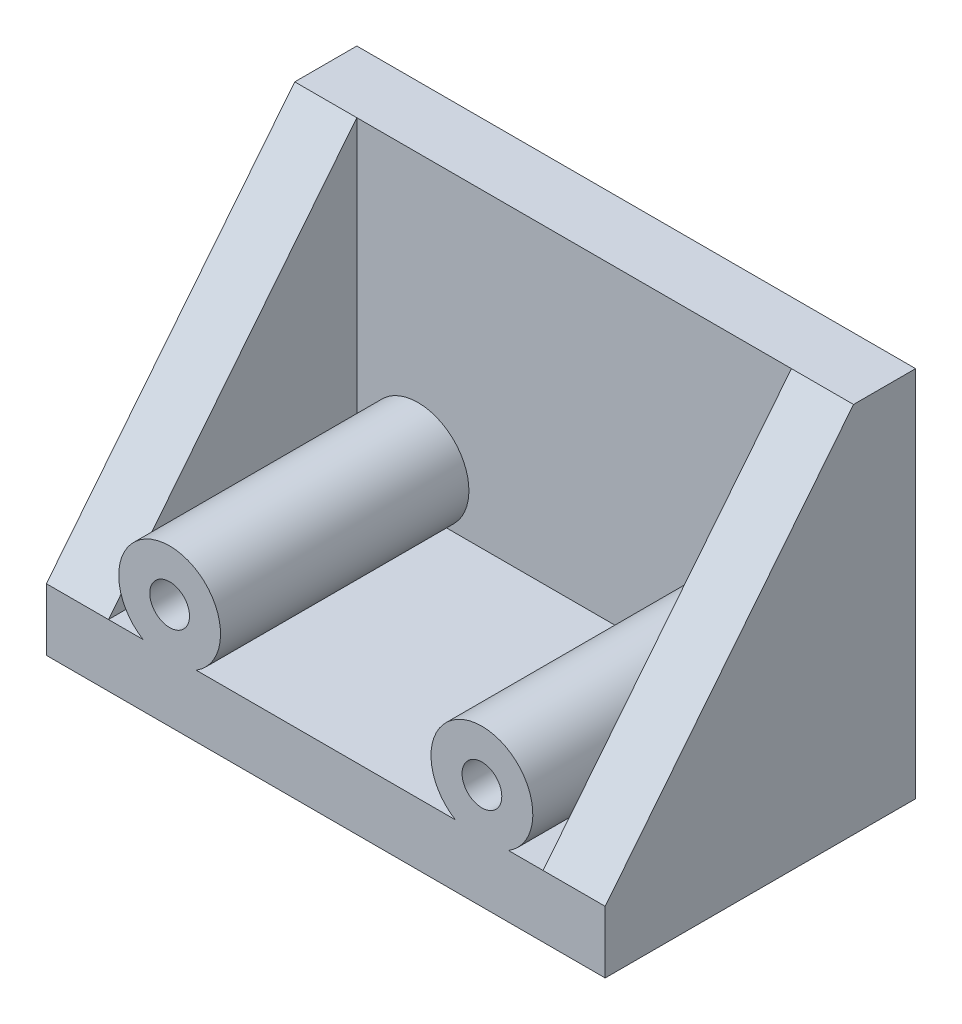
from build123d import *

# Parameters (mm, degrees)
SKETCH1_W            = 180
SKETCH1_H            = 120
BOSS_EXTRUDE1_DEPTH  = 20
SKETCH4_W            = 180
SKETCH4_H            = 100
BOSS_EXTRUDE4_DEPTH  = 20
BOSS_EXTRUDE5_DEPTH  = 20
SKETCH6_R            = 6.4
BOSS_EXTRUDE11_DEPTH = 80


with BuildPart() as part:
    # Sketch1 → Boss-Extrude1 (new body)
    with BuildSketch(Plane.XY):
        Rectangle(SKETCH1_W, SKETCH1_H)
    extrude(amount=BOSS_EXTRUDE1_DEPTH)

    # Sketch4 → Boss-Extrude4 (add)
    with BuildSketch(Plane(origin=(0, -60, 0), x_dir=(-1, 0, 0), z_dir=(0, -1, 0))):
        with Locations((0, -50)):
            Rectangle(SKETCH4_W, SKETCH4_H)
    extrude(amount=-BOSS_EXTRUDE4_DEPTH)

    # Sketch5 → Boss-Extrude5 (add)
    with BuildSketch(Plane(origin=(90, 0, 0), x_dir=(0, 0, -1), z_dir=(1, 0, 0))):
        Polygon((-100, -40), (-20, -40), (-20, 60), align=None)
    boss_extrude5 = extrude(amount=-BOSS_EXTRUDE5_DEPTH)

    # Mirror2: Boss-Extrude5 across plane
    add(boss_extrude5.mirror(Plane(origin=(0, 0, 0), x_dir=(0, 0, 1), z_dir=(1, 0, 0))))

    # Sketch6 → Boss-Extrude11 (add)
    with BuildSketch(Plane.XY.offset(20)):
        with BuildLine():
            Line((-41.754337398, -40), (-58.837662602, -40))
            ThreePointArc((-58.837662602, -40), (-50.296, -9.6), (-41.754337398, -40))
        make_face()
        with Locations((-50.296, -26)):
            Circle(SKETCH6_R, mode=Mode.SUBTRACT)
    boss_extrude11 = extrude(amount=BOSS_EXTRUDE11_DEPTH)

    # Mirror3: Boss-Extrude11 across plane
    add(boss_extrude11.mirror(Plane(origin=(0, 0, 0), x_dir=(0, 0, 1), z_dir=(1, 0, 0))))


solid = part.part
